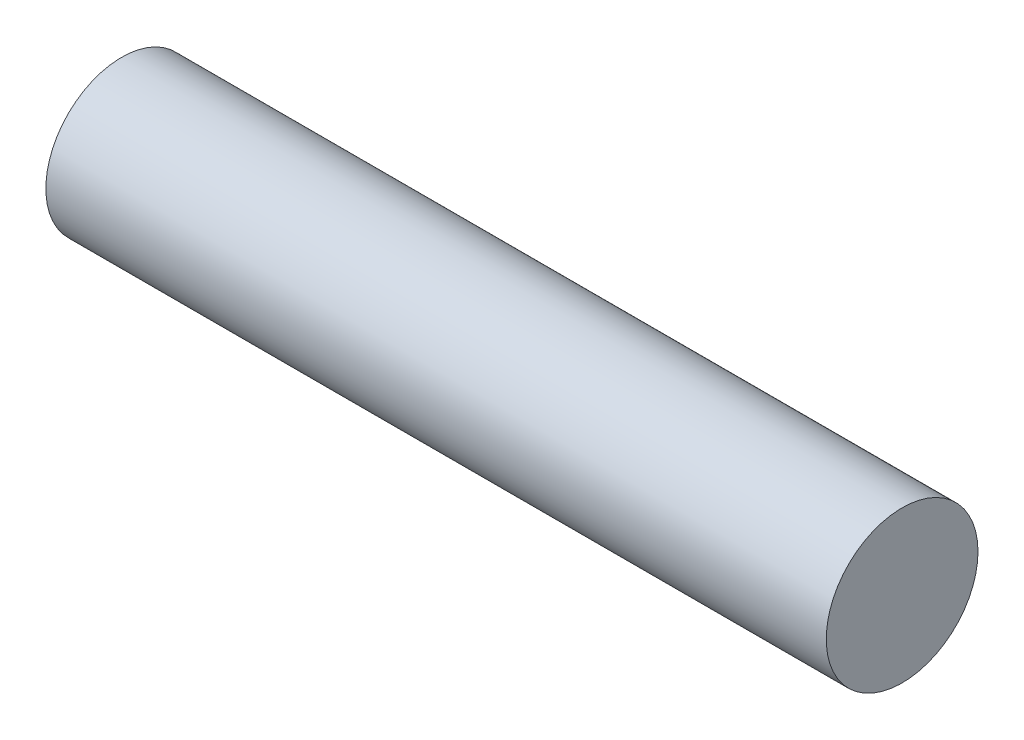
from build123d import *

# Parameters (mm, degrees)
SKETCH_1_R      = 0.875
EXTRUDE_1_DEPTH = 9


with BuildPart() as part:
    # Эскиз1 → Бобышка-Вытянуть1 (new body)
    with BuildSketch(Plane(origin=(0, 0, 0), x_dir=(0, 0, -1), z_dir=(1, 0, 0))):
        Circle(SKETCH_1_R)
    extrude(amount=EXTRUDE_1_DEPTH)


solid = part.part
